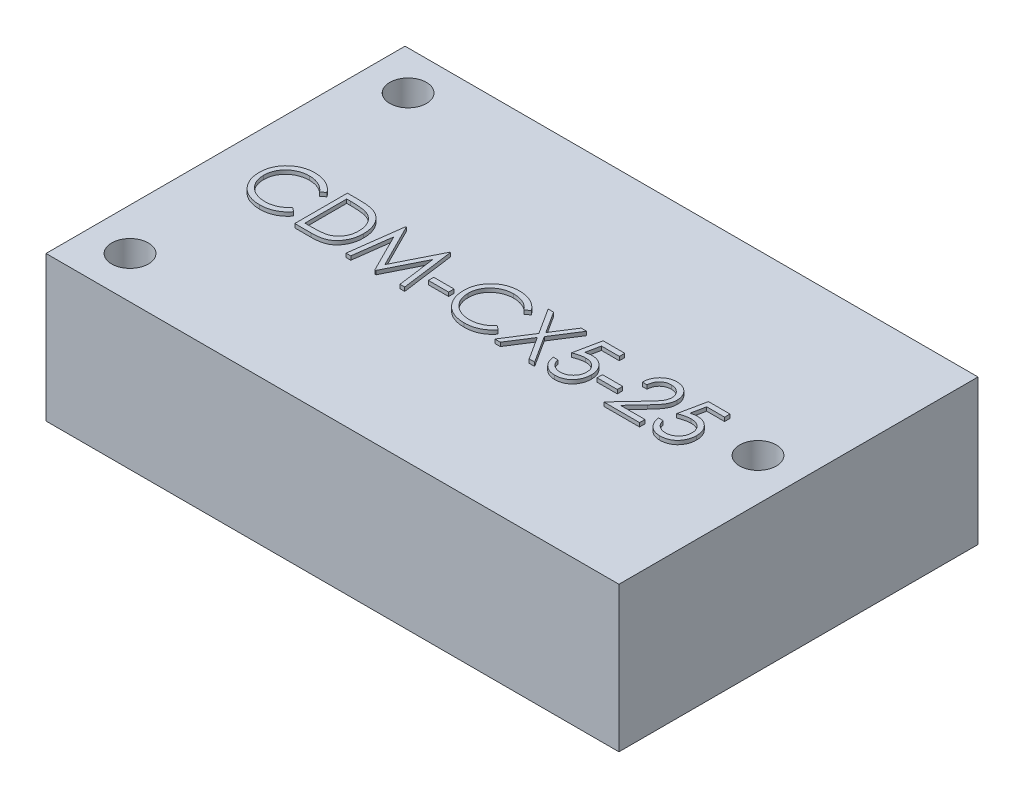
from build123d import *

# Parameters (mm, degrees)
SKETCH1_W           = 38.1
SKETCH1_H           = 23.876
SKETCH1_R           = 1.2192
BOSS_EXTRUDE1_DEPTH = 9.652
SKETCH2_W           = 1.346153846
SKETCH2_H           = 0.358974359
BOSS_EXTRUDE2_DEPTH = 0.254


with BuildPart() as part:
    # Sketch1 → Boss-Extrude1 (new body)
    with BuildSketch(Plane(origin=(0, 0, 0), x_dir=(1, 0, 0), z_dir=(0, 1, 0))):
        Rectangle(SKETCH1_W, SKETCH1_H)
        with Locations((-16.256, 9.3472)):
            Circle(SKETCH1_R, mode=Mode.SUBTRACT)
        with Locations((-16.256, -9.144)):
            Circle(SKETCH1_R, mode=Mode.SUBTRACT)
        with Locations((16.256, 0.1016)):
            Circle(SKETCH1_R, mode=Mode.SUBTRACT)
    extrude(amount=-BOSS_EXTRUDE1_DEPTH)

    # Sketch2 → Boss-Extrude2 (add)
    with BuildSketch(Plane(origin=(0, 0, 0), x_dir=(1, 0, 0), z_dir=(0, 1, 0))):
        with BuildLine():
            Line((-12.967255042, 0.660782807), (-13.242094786, 0.450446269))
            add(Edge.make_bspline(
                [(-13.242094786, 0.450446269), (-13.261700674, 0.473812239), (-13.300648121, 0.520229154), (-13.363307324, 0.585408699), (-13.428608966, 0.64647396), (-13.496528088, 0.70371584), (-13.568287207, 0.755132606), (-13.642148006, 0.803403708), (-13.719346051, 0.846671446), (-13.826097786, 0.899134433), (-13.965745634, 0.953880588), (-14.141540473, 0.999783819), (-14.325051572, 1.029004995), (-14.450249171, 1.032169836), (-14.513929722, 1.033779602)],
                knots=[0, 0, 0, 0, 9.1485e-05, 0.000181737, 0.000271024, 0.000359627, 0.000447979, 0.000535687, 0.000624217, 0.000713268, 0.000892422, 0.00107303, 0.001257466, 0.001448389, 0.001448389, 0.001448389, 0.001448389], degree=3))
            add(Edge.make_bspline(
                [(-14.513929722, 1.033779602), (-14.549013021, 1.03337564), (-14.618854014, 1.032571464), (-14.722502487, 1.021962338), (-14.824215538, 1.007051128), (-14.923927005, 0.984925805), (-15.021509963, 0.956953186), (-15.117602365, 0.923527772), (-15.210812965, 0.882172932), (-15.302431203, 0.836464672), (-15.390210414, 0.784837228), (-15.473265462, 0.728523876), (-15.55129343, 0.668154779), (-15.624356042, 0.603503673), (-15.69252799, 0.534861712), (-15.755315301, 0.461497371), (-15.812500711, 0.383645197), (-15.865217736, 0.30233179), (-15.91243047, 0.217793998), (-15.951960349, 0.129718928), (-15.986965471, 0.039614825), (-16.014664714, -0.053536336), (-16.036589231, -0.149079102), (-16.051716894, -0.24726989), (-16.062205365, -0.347903569), (-16.063005542, -0.416112882), (-16.063408888, -0.450495238)],
                knots=[0, 0, 0, 0, 0.000105206, 0.000209435, 0.000312261, 0.00041348, 0.000515565, 0.000616682, 0.000718413, 0.000821258, 0.000923708, 0.001023662, 0.001122111, 0.001219464, 0.00131614, 0.001412112, 0.001508869, 0.001605718, 0.001702691, 0.001799013, 0.001895107, 0.001992482, 0.002090281, 0.00218895, 0.002290387, 0.00239349, 0.00239349, 0.00239349, 0.00239349], degree=3))
            add(Edge.make_bspline(
                [(-16.063408888, -0.450495238), (-16.062147069, -0.502226558), (-16.059669655, -0.603794142), (-16.037621321, -0.752564753), (-16.00411623, -0.895085427), (-15.953900653, -1.030465269), (-15.891981602, -1.160373627), (-15.813740991, -1.282612481), (-15.723124453, -1.399029045), (-15.618850034, -1.506871993), (-15.504444218, -1.605385718), (-15.381696306, -1.6921363), (-15.250912019, -1.764451182), (-15.113535388, -1.824627129), (-14.968509274, -1.870883856), (-14.816094472, -1.90344798), (-14.656622477, -1.92469016), (-14.547653077, -1.926723848), (-14.492194946, -1.927758859)],
                knots=[0, 0, 0, 0, 0.000155106, 0.000304531, 0.000450265, 0.000593548, 0.000736853, 0.000881182, 0.001028026, 0.001178769, 0.001330408, 0.001480379, 0.001628835, 0.001777978, 0.001929641, 0.002084627, 0.002245075, 0.00241136, 0.00241136, 0.00241136, 0.00241136], degree=3))
            add(Edge.make_bspline(
                [(-14.492194946, -1.927758859), (-14.431092257, -1.92607008), (-14.310827548, -1.922746157), (-14.134459522, -1.894586908), (-13.965623756, -1.84892899), (-13.80431117, -1.785031068), (-13.650976523, -1.70196578), (-13.505379863, -1.601267903), (-13.367398293, -1.48197957), (-13.28442701, -1.390896442), (-13.242094786, -1.344425526)],
                knots=[0, 0, 0, 0, 0.00018322, 0.00036062, 0.000534275, 0.000707044, 0.000879893, 0.001056289, 0.001237208, 0.001425665, 0.001425665, 0.001425665, 0.001425665], degree=3))
            Line((-13.242094786, -1.344425526), (-12.967255042, -1.552658699))
            add(Edge.make_bspline(
                [(-12.967255042, -1.552658699), (-12.989373152, -1.581197151), (-13.033503427, -1.638137357), (-13.104961444, -1.718409067), (-13.180238742, -1.793913103), (-13.259894452, -1.864040724), (-13.343012243, -1.930195189), (-13.431084556, -1.990497021), (-13.522953588, -2.045787905), (-13.618308067, -2.09641483), (-13.71704668, -2.141332077), (-13.819051115, -2.179785844), (-13.92388169, -2.212910734), (-14.031543199, -2.240162671), (-14.142258956, -2.261433754), (-14.25562943, -2.275653429), (-14.371899305, -2.285395344), (-14.450340726, -2.28628326), (-14.490091581, -2.286733218)],
                knots=[0, 0, 0, 0, 0.000108293, 0.000216068, 0.000322162, 0.000427957, 0.000534281, 0.00064066, 0.000747915, 0.000855806, 0.000964371, 0.001073102, 0.001182643, 0.001294024, 0.001406092, 0.001520624, 0.001636667, 0.001755891, 0.001755891, 0.001755891, 0.001755891], degree=3))
            add(Edge.make_bspline(
                [(-14.490091581, -2.286733218), (-14.527735248, -2.286471226), (-14.602170938, -2.285953168), (-14.712069689, -2.277561001), (-14.81905927, -2.266111264), (-14.922833896, -2.248871133), (-15.023959871, -2.228526793), (-15.121520456, -2.201255536), (-15.216475666, -2.170706369), (-15.308444007, -2.134801383), (-15.397503707, -2.0942852), (-15.483367518, -2.048493641), (-15.56599595, -1.997811777), (-15.646201371, -1.943356766), (-15.722798955, -1.883379464), (-15.79645248, -1.81871283), (-15.867574956, -1.749574819), (-15.911577641, -1.699719966), (-15.933701356, -1.674653892)],
                knots=[0, 0, 0, 0, 0.0001129, 0.000223246, 0.000330481, 0.000435603, 0.000538732, 0.000639764, 0.000739316, 0.000837878, 0.000935767, 0.001032686, 0.001129604, 0.00122645, 0.001323362, 0.001421241, 0.001520399, 0.001620667, 0.001620667, 0.001620667, 0.001620667], degree=3))
            add(Edge.make_bspline(
                [(-15.933701356, -1.674653892), (-15.969137, -1.631112703), (-16.039580477, -1.544555992), (-16.12970616, -1.404270011), (-16.206853715, -1.257801802), (-16.269229636, -1.104381873), (-16.317992369, -0.944354486), (-16.351773564, -0.777638972), (-16.373725169, -0.604391029), (-16.376235458, -0.486554241), (-16.377511453, -0.426657097)],
                knots=[0, 0, 0, 0, 0.000168306, 0.00033458, 0.000499224, 0.000664315, 0.00083066, 0.00100034, 0.001174094, 0.001353718, 0.001353718, 0.001353718, 0.001353718], degree=3))
            add(Edge.make_bspline(
                [(-16.377511453, -0.426657097), (-16.375956259, -0.363701643), (-16.372896513, -0.239840719), (-16.346900717, -0.058066765), (-16.305081921, 0.116084634), (-16.245685032, 0.282288378), (-16.170379681, 0.441418658), (-16.077353067, 0.592259863), (-15.967685925, 0.735776663), (-15.842238357, 0.869791414), (-15.704671022, 0.992330767), (-15.557352208, 1.100136971), (-15.400570261, 1.189854487), (-15.23605241, 1.264850649), (-15.062566728, 1.322495112), (-14.880483359, 1.362848299), (-14.690144444, 1.387965415), (-14.560282018, 1.391140623), (-14.494298311, 1.392753961)],
                knots=[0, 0, 0, 0, 0.000188789, 0.000371431, 0.000549644, 0.000725278, 0.00089996, 0.001076844, 0.001255917, 0.001440951, 0.001626689, 0.001807878, 0.001987546, 0.002167657, 0.002349462, 0.002534866, 0.002726448, 0.002924344, 0.002924344, 0.002924344, 0.002924344], degree=3))
            add(Edge.make_bspline(
                [(-14.494298311, 1.392753961), (-14.45408384, 1.392271823), (-14.374483342, 1.391317479), (-14.25673069, 1.382011337), (-14.142088363, 1.366497731), (-14.030477381, 1.345381661), (-13.921354765, 1.319174339), (-13.815554524, 1.285034041), (-13.712455837, 1.24599751), (-13.612708929, 1.201039044), (-13.516792379, 1.150572302), (-13.42473606, 1.095156679), (-13.337271201, 1.034860873), (-13.253782353, 0.970197698), (-13.175666142, 0.899799139), (-13.100704663, 0.825601543), (-13.031443585, 0.745467718), (-12.98869039, 0.689062784), (-12.967255042, 0.660782807)],
                knots=[0, 0, 0, 0, 0.000120626, 0.000238766, 0.000354085, 0.000467531, 0.000579423, 0.000690512, 0.000800803, 0.000910007, 0.001018518, 0.001125773, 0.001232152, 0.001337058, 0.001442329, 0.001547432, 0.001653292, 0.001759736, 0.001759736, 0.001759736, 0.001759736], degree=3))
        make_face()
        with BuildLine():
            Line((-12.249306324, -2.196989629), (-12.249306324, 1.303010371))
            Line((-12.249306324, 1.303010371), (-11.542575555, 1.303010371))
            add(Edge.make_bspline(
                [(-11.542575555, 1.303010371), (-11.481106567, 1.302567801), (-11.362348802, 1.301712758), (-11.190736354, 1.296291367), (-11.031952592, 1.286700901), (-10.886519733, 1.272731375), (-10.754038521, 1.255578342), (-10.634879912, 1.234077937), (-10.52842777, 1.208689767), (-10.462958329, 1.187044317), (-10.431998632, 1.176808448)],
                knots=[0, 0, 0, 0, 0.000184407, 0.000356273, 0.000515031, 0.000661537, 0.000794508, 0.000915664, 0.001024665, 0.001122454, 0.001122454, 0.001122454, 0.001122454], degree=3))
            add(Edge.make_bspline(
                [(-10.431998632, 1.176808448), (-10.391503893, 1.161377743), (-10.3114327, 1.130866249), (-10.197425578, 1.073309947), (-10.090100215, 1.008096845), (-9.98888107, 0.935140983), (-9.896080244, 0.852376634), (-9.808072347, 0.763319549), (-9.728457623, 0.664731208), (-9.655549327, 0.55865622), (-9.589813668, 0.446344168), (-9.53267451, 0.32800906), (-9.485220516, 0.204251851), (-9.44582729, 0.075416703), (-9.414780832, -0.058779674), (-9.393598901, -0.19849354), (-9.379627911, -0.34317273), (-9.378223859, -0.441347194), (-9.377511453, -0.491160302)],
                knots=[0, 0, 0, 0, 0.000129935, 0.000256923, 0.000382457, 0.000506429, 0.000630624, 0.000755071, 0.000881654, 0.001010204, 0.001140916, 0.00127168, 0.001403968, 0.001538146, 0.001675568, 0.001816774, 0.001961818, 0.002111216, 0.002111216, 0.002111216, 0.002111216], degree=3))
            add(Edge.make_bspline(
                [(-9.377511453, -0.491160302), (-9.37814042, -0.53442154), (-9.379379866, -0.619672329), (-9.390509182, -0.745313225), (-9.406685502, -0.867226796), (-9.4317297, -0.984832496), (-9.462132213, -1.099160714), (-9.501096365, -1.208992958), (-9.545731861, -1.315336768), (-9.597781739, -1.416754244), (-9.654923124, -1.512837616), (-9.716244868, -1.603413144), (-9.781681563, -1.687188366), (-9.851857196, -1.764416978), (-9.925864912, -1.834982556), (-10.004189243, -1.899474572), (-10.087032294, -1.956631127), (-10.174023016, -2.008698235), (-10.267699146, -2.05411859), (-10.369835012, -2.0925486), (-10.48086619, -2.124395215), (-10.600520147, -2.150966111), (-10.729003624, -2.172043414), (-10.86644259, -2.186169806), (-11.01262588, -2.195722739), (-11.113005145, -2.196559132), (-11.164670908, -2.196989629)],
                knots=[0, 0, 0, 0, 0.000129755, 0.000255696, 0.000378151, 0.000498469, 0.000616165, 0.000732801, 0.000847787, 0.000961923, 0.00107447, 0.001182981, 0.001289856, 0.001393094, 0.001495748, 0.001596383, 0.00169713, 0.001797413, 0.001900265, 0.002008995, 0.002124372, 0.002246504, 0.002376522, 0.002514729, 0.002660846, 0.00281582, 0.00281582, 0.00281582, 0.00281582], degree=3))
            Line((-11.164670908, -2.196989629), (-12.249306324, -2.196989629))
        make_face()
        with BuildLine():
            Line((-11.93520376, -1.83801527), (-11.533460972, -1.83801527))
            add(Edge.make_bspline(
                [(-11.533460972, -1.83801527), (-11.475732601, -1.837767173), (-11.364699803, -1.837289993), (-11.205041805, -1.83310279), (-11.059162409, -1.826260853), (-10.927040899, -1.816685775), (-10.808751875, -1.80401716), (-10.704048125, -1.789892257), (-10.613272867, -1.772294806), (-10.55834343, -1.756343847), (-10.53296017, -1.748972802)],
                knots=[0, 0, 0, 0, 0.000173183, 0.000333094, 0.000479096, 0.000611272, 0.000730431, 0.000835931, 0.000928194, 0.001007458, 0.001007458, 0.001007458, 0.001007458], degree=3))
            add(Edge.make_bspline(
                [(-10.53296017, -1.748972802), (-10.501011808, -1.737721244), (-10.43787817, -1.71548687), (-10.346997085, -1.674929209), (-10.26224008, -1.626887139), (-10.182130055, -1.573484865), (-10.1078034, -1.512838863), (-10.038379283, -1.446267875), (-9.973997482, -1.373433099), (-9.915323174, -1.294424938), (-9.86281487, -1.209735142), (-9.817343641, -1.120196309), (-9.777492109, -1.026789498), (-9.746213516, -0.92808034), (-9.721697932, -0.824951281), (-9.704333244, -0.717395068), (-9.69351852, -0.605431786), (-9.692257072, -0.529279662), (-9.691614017, -0.49045918)],
                knots=[0, 0, 0, 0, 0.000101593, 0.000200759, 0.000298073, 0.000393552, 0.000489254, 0.000585454, 0.000681817, 0.000780535, 0.000880346, 0.000980374, 0.001081551, 0.001184655, 0.001290601, 0.001399295, 0.001511268, 0.001627707, 0.001627707, 0.001627707, 0.001627707], degree=3))
            add(Edge.make_bspline(
                [(-9.691614017, -0.49045918), (-9.692127304, -0.4495257), (-9.693135662, -0.369111515), (-9.705809972, -0.25112082), (-9.724331527, -0.13764017), (-9.751115214, -0.028661974), (-9.785246092, 0.076026378), (-9.827840734, 0.175845888), (-9.876507353, 0.271850757), (-9.93441069, 0.361825123), (-9.997826284, 0.446918232), (-10.068204163, 0.524873148), (-10.144426201, 0.595867448), (-10.225661051, 0.661006761), (-10.31419815, 0.717670436), (-10.407951841, 0.768357117), (-10.508297512, 0.811373009), (-10.578110208, 0.834251872), (-10.613589177, 0.845878961)],
                knots=[0, 0, 0, 0, 0.000122746, 0.000241136, 0.000355593, 0.000467485, 0.000577457, 0.000685538, 0.00079278, 0.000899951, 0.001006101, 0.00111085, 0.001214524, 0.001318328, 0.001422759, 0.001529413, 0.00163777, 0.001749741, 0.001749741, 0.001749741, 0.001749741], degree=3))
            add(Edge.make_bspline(
                [(-10.613589177, 0.845878961), (-10.642940323, 0.853995389), (-10.705348914, 0.871253141), (-10.807188378, 0.890078514), (-10.921803527, 0.906683013), (-11.049703228, 0.920741052), (-11.190741687, 0.930828374), (-11.345027375, 0.938399688), (-11.51262698, 0.943506321), (-11.628809514, 0.943855028), (-11.68911001, 0.944036012)],
                knots=[0, 0, 0, 0, 9.1321e-05, 0.000194173, 0.000310382, 0.000438754, 0.000580072, 0.000734511, 0.000902151, 0.001083046, 0.001083046, 0.001083046, 0.001083046], degree=3))
            Line((-11.68911001, 0.944036012), (-11.93520376, 0.944036012))
            Line((-11.93520376, 0.944036012), (-11.93520376, -1.83801527))
        make_face(mode=Mode.SUBTRACT)
        Polygon((-8.839049914, -2.196989629), (-8.377010651, 1.303010371), (-8.332138856, 1.303010371), (-6.887126837, -1.5687845), (-5.445620427, 1.303010371), (-5.40004751, 1.303010371), (-4.93520376, -2.196989629), (-5.250708568, -2.196989629), (-5.585844786, 0.321439858), (-6.84926626, -2.196989629), (-6.920079561, -2.196989629), (-8.188408888, 0.327048833), (-8.522843985, -2.196989629), align=None)
        with Locations((-3.858280683, -0.850835783)):
            Rectangle(SKETCH2_W, SKETCH2_H)
        with BuildLine():
            Line((0.628898804, 0.660782807), (0.35405906, 0.450446269))
            add(Edge.make_bspline(
                [(0.35405906, 0.450446269), (0.334453172, 0.473812239), (0.295505725, 0.520229154), (0.232846523, 0.585408699), (0.16754488, 0.64647396), (0.099625758, 0.70371584), (0.027866639, 0.755132606), (-0.04599416, 0.803403708), (-0.123192205, 0.846671446), (-0.22994394, 0.899134433), (-0.369591788, 0.953880588), (-0.545386627, 0.999783819), (-0.728897725, 1.029004995), (-0.854095325, 1.032169836), (-0.917775876, 1.033779602)],
                knots=[0, 0, 0, 0, 9.1485e-05, 0.000181737, 0.000271024, 0.000359627, 0.000447979, 0.000535687, 0.000624217, 0.000713268, 0.000892422, 0.00107303, 0.001257466, 0.001448389, 0.001448389, 0.001448389, 0.001448389], degree=3))
            add(Edge.make_bspline(
                [(-0.917775876, 1.033779602), (-0.952859175, 1.03337564), (-1.022700168, 1.032571464), (-1.126348641, 1.021962338), (-1.228061692, 1.007051128), (-1.327773158, 0.984925805), (-1.425356117, 0.956953186), (-1.521448519, 0.923527772), (-1.614659119, 0.882172932), (-1.706277357, 0.836464672), (-1.794056568, 0.784837228), (-1.877111616, 0.728523876), (-1.955139584, 0.668154779), (-2.028202196, 0.603503673), (-2.096374144, 0.534861712), (-2.159161455, 0.461497371), (-2.216346865, 0.383645197), (-2.26906389, 0.30233179), (-2.316276624, 0.217793998), (-2.355806503, 0.129718928), (-2.390811625, 0.039614825), (-2.418510868, -0.053536336), (-2.440435385, -0.149079102), (-2.455563048, -0.24726989), (-2.466051519, -0.347903569), (-2.466851696, -0.416112882), (-2.467255042, -0.450495238)],
                knots=[0, 0, 0, 0, 0.000105206, 0.000209435, 0.000312261, 0.00041348, 0.000515565, 0.000616682, 0.000718413, 0.000821258, 0.000923708, 0.001023662, 0.001122111, 0.001219464, 0.00131614, 0.001412112, 0.001508869, 0.001605718, 0.001702691, 0.001799013, 0.001895107, 0.001992482, 0.002090281, 0.00218895, 0.002290387, 0.00239349, 0.00239349, 0.00239349, 0.00239349], degree=3))
            add(Edge.make_bspline(
                [(-2.467255042, -0.450495238), (-2.465993223, -0.502226558), (-2.463515809, -0.603794142), (-2.441467475, -0.752564753), (-2.407962384, -0.895085427), (-2.357746807, -1.030465269), (-2.295827756, -1.160373627), (-2.217587145, -1.282612481), (-2.126970607, -1.399029045), (-2.022696188, -1.506871993), (-1.908290372, -1.605385718), (-1.78554246, -1.6921363), (-1.654758172, -1.764451182), (-1.517381542, -1.824627129), (-1.372355428, -1.870883856), (-1.219940626, -1.90344798), (-1.060468631, -1.92469016), (-0.951499231, -1.926723848), (-0.8960411, -1.927758859)],
                knots=[0, 0, 0, 0, 0.000155106, 0.000304531, 0.000450265, 0.000593548, 0.000736853, 0.000881182, 0.001028026, 0.001178769, 0.001330408, 0.001480379, 0.001628835, 0.001777978, 0.001929641, 0.002084627, 0.002245075, 0.00241136, 0.00241136, 0.00241136, 0.00241136], degree=3))
            add(Edge.make_bspline(
                [(-0.8960411, -1.927758859), (-0.834938411, -1.92607008), (-0.714673702, -1.922746157), (-0.538305676, -1.894586908), (-0.36946991, -1.84892899), (-0.208157324, -1.785031068), (-0.054822677, -1.70196578), (0.090773983, -1.601267903), (0.228755553, -1.48197957), (0.311726836, -1.390896442), (0.35405906, -1.344425526)],
                knots=[0, 0, 0, 0, 0.00018322, 0.00036062, 0.000534275, 0.000707044, 0.000879893, 0.001056289, 0.001237208, 0.001425665, 0.001425665, 0.001425665, 0.001425665], degree=3))
            Line((0.35405906, -1.344425526), (0.628898804, -1.552658699))
            add(Edge.make_bspline(
                [(0.628898804, -1.552658699), (0.606780694, -1.581197151), (0.562650419, -1.638137357), (0.491192402, -1.718409067), (0.415915104, -1.793913103), (0.336259394, -1.864040724), (0.253141603, -1.930195189), (0.16506929, -1.990497021), (0.073200258, -2.045787905), (-0.022154221, -2.09641483), (-0.120892834, -2.141332077), (-0.222897269, -2.179785844), (-0.327727844, -2.212910734), (-0.435389353, -2.240162671), (-0.546105109, -2.261433754), (-0.659475584, -2.275653429), (-0.775745459, -2.285395344), (-0.85418688, -2.28628326), (-0.893937735, -2.286733218)],
                knots=[0, 0, 0, 0, 0.000108293, 0.000216068, 0.000322162, 0.000427957, 0.000534281, 0.00064066, 0.000747915, 0.000855806, 0.000964371, 0.001073102, 0.001182643, 0.001294024, 0.001406092, 0.001520624, 0.001636667, 0.001755891, 0.001755891, 0.001755891, 0.001755891], degree=3))
            add(Edge.make_bspline(
                [(-0.893937735, -2.286733218), (-0.931581402, -2.286471226), (-1.006017092, -2.285953168), (-1.115915843, -2.277561001), (-1.222905424, -2.266111264), (-1.32668005, -2.248871133), (-1.427806025, -2.228526793), (-1.52536661, -2.201255536), (-1.62032182, -2.170706369), (-1.712290161, -2.134801383), (-1.80134986, -2.0942852), (-1.887213672, -2.048493641), (-1.969842104, -1.997811777), (-2.050047525, -1.943356766), (-2.126645109, -1.883379464), (-2.200298634, -1.81871283), (-2.27142111, -1.749574819), (-2.315423795, -1.699719966), (-2.33754751, -1.674653892)],
                knots=[0, 0, 0, 0, 0.0001129, 0.000223246, 0.000330481, 0.000435603, 0.000538732, 0.000639764, 0.000739316, 0.000837878, 0.000935767, 0.001032686, 0.001129604, 0.00122645, 0.001323362, 0.001421241, 0.001520399, 0.001620667, 0.001620667, 0.001620667, 0.001620667], degree=3))
            add(Edge.make_bspline(
                [(-2.33754751, -1.674653892), (-2.372983154, -1.631112703), (-2.443426631, -1.544555992), (-2.533552314, -1.404270011), (-2.610699869, -1.257801802), (-2.67307579, -1.104381873), (-2.721838523, -0.944354486), (-2.755619718, -0.777638972), (-2.777571323, -0.604391029), (-2.780081612, -0.486554241), (-2.781357606, -0.426657097)],
                knots=[0, 0, 0, 0, 0.000168306, 0.00033458, 0.000499224, 0.000664315, 0.00083066, 0.00100034, 0.001174094, 0.001353718, 0.001353718, 0.001353718, 0.001353718], degree=3))
            add(Edge.make_bspline(
                [(-2.781357606, -0.426657097), (-2.779802413, -0.363701643), (-2.776742667, -0.239840719), (-2.750746871, -0.058066765), (-2.708928075, 0.116084634), (-2.649531186, 0.282288378), (-2.574225835, 0.441418658), (-2.481199221, 0.592259863), (-2.371532079, 0.735776663), (-2.246084511, 0.869791414), (-2.108517176, 0.992330767), (-1.961198362, 1.100136971), (-1.804416415, 1.189854487), (-1.639898563, 1.264850649), (-1.466412882, 1.322495112), (-1.284329513, 1.362848299), (-1.093990598, 1.387965415), (-0.964128172, 1.391140623), (-0.898144465, 1.392753961)],
                knots=[0, 0, 0, 0, 0.000188789, 0.000371431, 0.000549644, 0.000725278, 0.00089996, 0.001076844, 0.001255917, 0.001440951, 0.001626689, 0.001807878, 0.001987546, 0.002167657, 0.002349462, 0.002534866, 0.002726448, 0.002924344, 0.002924344, 0.002924344, 0.002924344], degree=3))
            add(Edge.make_bspline(
                [(-0.898144465, 1.392753961), (-0.857929993, 1.392271823), (-0.778329496, 1.391317479), (-0.660576844, 1.382011337), (-0.545934517, 1.366497731), (-0.434323535, 1.345381661), (-0.325200918, 1.319174339), (-0.219400678, 1.285034041), (-0.116301991, 1.24599751), (-0.016555083, 1.201039044), (0.079361468, 1.150572302), (0.171417786, 1.095156679), (0.258882645, 1.034860873), (0.342371493, 0.970197698), (0.420487704, 0.899799139), (0.495449183, 0.825601543), (0.564710261, 0.745467718), (0.607463456, 0.689062784), (0.628898804, 0.660782807)],
                knots=[0, 0, 0, 0, 0.000120626, 0.000238766, 0.000354085, 0.000467531, 0.000579423, 0.000690512, 0.000800803, 0.000910007, 0.001018518, 0.001125773, 0.001232152, 0.001337058, 0.001442329, 0.001547432, 0.001653292, 0.001759736, 0.001759736, 0.001759736, 0.001759736], degree=3))
        make_face()
        Polygon((1.10005265, 1.303010371), (1.462532618, 1.303010371), (2.378898804, -0.128680334), (3.29526499, 1.303010371), (3.657744958, 1.303010371), (2.560489349, -0.411933539), (3.702616753, -2.196989629), (3.340136785, -2.196989629), (2.378898804, -0.695186744), (1.417660823, -2.196989629), (1.055180855, -2.196989629), (2.198009381, -0.411933539), align=None)
        with BuildLine():
            Line((6.193001368, 1.303010371), (6.193001368, 0.944036012))
            Line((6.193001368, 0.944036012), (5.00249656, 0.944036012))
            Line((5.00249656, 0.944036012), (4.813894797, 0.023463096))
            add(Edge.make_bspline(
                [(4.813894797, 0.023463096), (4.850950672, 0.033693367), (4.922740568, 0.053512901), (5.028700429, 0.075518672), (5.129292632, 0.088784116), (5.194568003, 0.090595426), (5.226154413, 0.09147191)],
                knots=[0, 0, 0, 0, 0.000115302, 0.000223379, 0.000324431, 0.000419176, 0.000419176, 0.000419176, 0.000419176], degree=3))
            add(Edge.make_bspline(
                [(5.226154413, 0.09147191), (5.265238153, 0.090625974), (5.34208655, 0.088962653), (5.454525497, 0.072990804), (5.56185839, 0.047850889), (5.66386076, 0.012730367), (5.760721311, -0.032179366), (5.851548872, -0.088279306), (5.937706785, -0.153812637), (6.017649379, -0.229157649), (6.090173688, -0.312079266), (6.153939677, -0.401237137), (6.208102267, -0.495764799), (6.251663022, -0.596565408), (6.286447357, -0.702524561), (6.309599351, -0.814757144), (6.32501606, -0.932205264), (6.326738447, -1.012509834), (6.327616753, -1.053459981)],
                knots=[0, 0, 0, 0, 0.00011719, 0.000230425, 0.000339944, 0.000447481, 0.000553499, 0.000659556, 0.000767111, 0.000877722, 0.000988528, 0.001097091, 0.001206056, 0.001314692, 0.001425996, 0.001539995, 0.001658004, 0.001780798, 0.001780798, 0.001780798, 0.001780798], degree=3))
            add(Edge.make_bspline(
                [(6.327616753, -1.053459981), (6.326951677, -1.081982202), (6.325630515, -1.138641189), (6.318911927, -1.22278539), (6.305976211, -1.305148223), (6.288608487, -1.385740615), (6.266066069, -1.464409987), (6.238777015, -1.541381515), (6.205380988, -1.616176122), (6.168749612, -1.689501517), (6.127503134, -1.759700024), (6.081724627, -1.82534901), (6.033359136, -1.887433292), (5.98131775, -1.945287025), (5.925116755, -1.998530043), (5.865436788, -2.047478324), (5.802754069, -2.092959655), (5.736098827, -2.13312785), (5.666956344, -2.170090806), (5.594328127, -2.200414343), (5.519867426, -2.227524871), (5.442502551, -2.249134399), (5.362408738, -2.266066953), (5.279453963, -2.277567554), (5.194073293, -2.285943992), (5.13619828, -2.286468348), (5.106963708, -2.286733218)],
                knots=[0, 0, 0, 0, 8.5583e-05, 0.000170009, 0.000253005, 0.000335518, 0.000417186, 0.000498352, 0.000580291, 0.000662755, 0.000744161, 0.000824288, 0.000902692, 0.000980133, 0.001057498, 0.001134702, 0.00121156, 0.001289599, 0.001368002, 0.001446531, 0.001525481, 0.001605609, 0.001687289, 0.001770875, 0.001856759, 0.001944425, 0.001944425, 0.001944425, 0.001944425], degree=3))
            add(Edge.make_bspline(
                [(5.106963708, -2.286733218), (5.072089527, -2.28604238), (5.003478696, -2.284683238), (4.902958129, -2.270464753), (4.806243524, -2.250100837), (4.714113422, -2.219464567), (4.625742159, -2.181077272), (4.542319441, -2.132561101), (4.461713665, -2.077581997), (4.387201628, -2.012701644), (4.318045515, -1.941785962), (4.256139006, -1.864828321), (4.201005429, -1.783098879), (4.153527682, -1.696200725), (4.113029661, -1.604362194), (4.081214672, -1.507239193), (4.055536318, -1.405339189), (4.044672897, -1.335185678), (4.039155214, -1.299553731)],
                knots=[0, 0, 0, 0, 0.000104552, 0.000205693, 0.000304023, 0.000400691, 0.00049644, 0.000592535, 0.000689779, 0.000788716, 0.000888377, 0.000986596, 0.001084603, 0.001183757, 0.001283279, 0.001385267, 0.001490017, 0.001598135, 0.001598135, 0.001598135, 0.001598135], degree=3))
            Line((4.039155214, -1.299553731), (4.353257778, -1.299553731))
            add(Edge.make_bspline(
                [(4.353257778, -1.299553731), (4.360986336, -1.332930184), (4.375841052, -1.397081579), (4.408446801, -1.48721292), (4.448312676, -1.567532144), (4.495717025, -1.639101727), (4.552267055, -1.701510724), (4.616796484, -1.757127786), (4.689144207, -1.807302915), (4.769537437, -1.849125683), (4.854350516, -1.884794436), (4.943117726, -1.908546131), (5.033422073, -1.925247024), (5.094500443, -1.926918785), (5.125192874, -1.927758859)],
                knots=[0, 0, 0, 0, 0.000102709, 0.000197412, 0.000286774, 0.000371169, 0.000454082, 0.000538572, 0.000626283, 0.000717552, 0.000809994, 0.00090168, 0.00099274, 0.001084718, 0.001084718, 0.001084718, 0.001084718], degree=3))
            add(Edge.make_bspline(
                [(5.125192874, -1.927758859), (5.155151319, -1.926938082), (5.214139741, -1.925321963), (5.300951128, -1.912882951), (5.384764002, -1.89372538), (5.464751359, -1.865055525), (5.542312898, -1.830210806), (5.615486669, -1.785495731), (5.686389546, -1.734035712), (5.752817679, -1.675079082), (5.813657129, -1.610109387), (5.86741325, -1.540631994), (5.912190163, -1.466515147), (5.949924272, -1.389041995), (5.978577571, -1.307363437), (5.999018552, -1.221862262), (6.011021611, -1.132327282), (6.012672791, -1.071257972), (6.013514189, -1.040138667)],
                knots=[0, 0, 0, 0, 8.9842e-05, 0.0001769, 0.000262612, 0.000347317, 0.000431396, 0.000517249, 0.000604055, 0.000693954, 0.000783242, 0.000870748, 0.000956963, 0.001042571, 0.001128832, 0.00121607, 0.001305907, 0.001399251, 0.001399251, 0.001399251, 0.001399251], degree=3))
            add(Edge.make_bspline(
                [(6.013514189, -1.040138667), (6.012855709, -1.012062916), (6.011566829, -0.957108626), (6.001036259, -0.87670942), (5.982719287, -0.800636378), (5.957295407, -0.728522144), (5.925015899, -0.660298701), (5.885569587, -0.595895641), (5.838216189, -0.536161808), (5.7841243, -0.481069254), (5.724866259, -0.43022438), (5.659422516, -0.386880293), (5.58916259, -0.350416375), (5.51493299, -0.318948377), (5.434968092, -0.296347632), (5.350851459, -0.279379746), (5.261674751, -0.269564384), (5.200704063, -0.268202495), (5.169363547, -0.267502449)],
                knots=[0, 0, 0, 0, 8.4208e-05, 0.000164824, 0.000242709, 0.000318547, 0.000393815, 0.000468731, 0.000544614, 0.00062196, 0.000700062, 0.000778428, 0.000856831, 0.000937299, 0.001019835, 0.001105635, 0.00119452, 0.001288536, 0.001288536, 0.001288536, 0.001288536], degree=3))
            add(Edge.make_bspline(
                [(5.169363547, -0.267502449), (5.142234619, -0.26808304), (5.086220263, -0.269281814), (5.000297437, -0.278108311), (4.910005714, -0.292347605), (4.815691218, -0.311933853), (4.71707071, -0.337564929), (4.614352309, -0.36827943), (4.507320043, -0.405001429), (4.435202318, -0.432733642), (4.398129573, -0.446989629)],
                knots=[0, 0, 0, 0, 8.1378e-05, 0.000168026, 0.000258858, 0.000355524, 0.000456875, 0.000564457, 0.000677092, 0.000796243, 0.000796243, 0.000796243, 0.000796243], degree=3))
            Line((4.398129573, -0.446989629), (4.757103932, 1.303010371))
            Line((4.757103932, 1.303010371), (6.193001368, 1.303010371))
        make_face()
        with Locations((7.359668035, -0.850835783)):
            Rectangle(SKETCH2_W, SKETCH2_H)
        with BuildLine():
            Line((8.750693676, 0.226087294), (8.436591112, 0.226087294))
            add(Edge.make_bspline(
                [(8.436591112, 0.226087294), (8.438638265, 0.267758182), (8.442658819, 0.349598697), (8.461487108, 0.468922603), (8.488427985, 0.582977402), (8.526519439, 0.690847316), (8.573825717, 0.793486123), (8.630555744, 0.890486139), (8.697749595, 0.981477327), (8.773956329, 1.065616171), (8.856724968, 1.142803742), (8.946030907, 1.209458984), (9.039875935, 1.265776656), (9.137975334, 1.312857898), (9.241435897, 1.348197743), (9.349318755, 1.374419383), (9.462097891, 1.390195729), (9.538937913, 1.391891514), (9.578017394, 1.392753961)],
                knots=[0, 0, 0, 0, 0.000125083, 0.00024566, 0.000361805, 0.000476223, 0.000588214, 0.000700404, 0.000812728, 0.00092691, 0.001040529, 0.001151727, 0.001260545, 0.001368429, 0.001477521, 0.001587884, 0.001701119, 0.00181831, 0.00181831, 0.00181831, 0.00181831], degree=3))
            add(Edge.make_bspline(
                [(9.578017394, 1.392753961), (9.616395468, 1.391855505), (9.691807012, 1.39009007), (9.801869027, 1.374929041), (9.906646321, 1.351183449), (10.005934088, 1.317868033), (10.098940152, 1.273083605), (10.186363197, 1.219286067), (10.269244008, 1.157066235), (10.343850791, 1.083812422), (10.412358871, 1.005610037), (10.471461126, 0.922122134), (10.522074289, 0.835892848), (10.564261969, 0.746264646), (10.595318108, 0.652393618), (10.618896316, 0.555646415), (10.63222373, 0.455021604), (10.634269153, 0.386915048), (10.63530906, 0.352289217)],
                knots=[0, 0, 0, 0, 0.000115089, 0.000226145, 0.000332614, 0.000437044, 0.000539592, 0.000641561, 0.000744629, 0.00084975, 0.000954621, 0.001056175, 0.001156101, 0.001254284, 0.001352726, 0.001452208, 0.001552655, 0.001656537, 0.001656537, 0.001656537, 0.001656537], degree=3))
            add(Edge.make_bspline(
                [(10.63530906, 0.352289217), (10.633615797, 0.303541383), (10.630258986, 0.206901169), (10.60154461, 0.064886306), (10.556698098, -0.072707113), (10.502700742, -0.183444415), (10.448228298, -0.272677908), (10.39914079, -0.346146613), (10.341675979, -0.425252082), (10.274997481, -0.509729419), (10.200484609, -0.600240324), (10.117462445, -0.69673012), (10.025338963, -0.798201889), (9.960680463, -0.867507491), (9.927176047, -0.903419917)],
                knots=[0, 0, 0, 0, 0.000146118, 0.000289672, 0.0004329, 0.00057934, 0.000657978, 0.000746456, 0.000844345, 0.000951219, 0.001069268, 0.00119604, 0.001333047, 0.001480391, 0.001480391, 0.001480391, 0.001480391], degree=3))
            Line((9.927176047, -0.903419917), (9.051474926, -1.83801527))
            Line((9.051474926, -1.83801527), (10.680180855, -1.83801527))
            Line((10.680180855, -1.83801527), (10.680180855, -2.196989629))
            Line((10.680180855, -2.196989629), (8.301975727, -2.196989629))
            Line((8.301975727, -2.196989629), (9.659347522, -0.748472))
            add(Edge.make_bspline(
                [(9.659347522, -0.748472), (9.692395409, -0.713973694), (9.755873636, -0.647709507), (9.845656213, -0.550966547), (9.926295201, -0.461217006), (9.998312594, -0.378630458), (10.060146099, -0.30199889), (10.115018331, -0.233804187), (10.158983922, -0.171049736), (10.206699318, -0.098309122), (10.252913299, -0.009496805), (10.292625655, 0.099036884), (10.316840504, 0.210764137), (10.319745339, 0.286266174), (10.321206496, 0.324244346)],
                knots=[0, 0, 0, 0, 0.000143319, 0.000275286, 0.00039593, 0.000505287, 0.000603949, 0.000691331, 0.000767782, 0.00083371, 0.000952247, 0.001067137, 0.001179618, 0.001293462, 0.001293462, 0.001293462, 0.001293462], degree=3))
            add(Edge.make_bspline(
                [(10.321206496, 0.324244346), (10.320570754, 0.348125744), (10.319317828, 0.395191394), (10.30826013, 0.464197153), (10.291549624, 0.530761967), (10.267604366, 0.595090586), (10.235997626, 0.656536238), (10.197524246, 0.715173719), (10.153134183, 0.771862684), (10.101782914, 0.825015982), (10.045371394, 0.873697187), (9.985777144, 0.916821273), (9.92272704, 0.952860384), (9.856486918, 0.982403881), (9.787241448, 1.005579262), (9.714856703, 1.021637841), (9.639532687, 1.031720325), (9.588099191, 1.033084497), (9.561891592, 1.033779602)],
                knots=[0, 0, 0, 0, 7.16e-05, 0.00014111, 0.00020913, 0.00027724, 0.000346538, 0.000415963, 0.000487357, 0.000562233, 0.000637292, 0.000710646, 0.000782564, 0.000854749, 0.000927915, 0.001001225, 0.001076884, 0.001155488, 0.001155488, 0.001155488, 0.001155488], degree=3))
            add(Edge.make_bspline(
                [(9.561891592, 1.033779602), (9.53452076, 1.03306457), (9.480768963, 1.031660365), (9.40184993, 1.021837701), (9.326564153, 1.00489186), (9.25472225, 0.981715186), (9.186202664, 0.952256637), (9.12133862, 0.915564892), (9.060275731, 0.871781399), (9.002899208, 0.822140843), (8.950035228, 0.766873242), (8.903588353, 0.705263278), (8.863004338, 0.638435863), (8.827595105, 0.566571313), (8.798839415, 0.489017533), (8.776866264, 0.406049828), (8.759479418, 0.318028446), (8.753670897, 0.257243361), (8.750693676, 0.226087294)],
                knots=[0, 0, 0, 0, 8.2106e-05, 0.000161243, 0.000238127, 0.000313291, 0.000387401, 0.000461495, 0.000536397, 0.000612445, 0.000688819, 0.000765383, 0.000843422, 0.000923066, 0.001005373, 0.001091093, 0.001180334, 0.001274175, 0.001274175, 0.001274175, 0.001274175], degree=3))
        make_face()
        with BuildLine():
            Line((13.193001368, 1.303010371), (13.193001368, 0.944036012))
            Line((13.193001368, 0.944036012), (12.00249656, 0.944036012))
            Line((12.00249656, 0.944036012), (11.813894797, 0.023463096))
            add(Edge.make_bspline(
                [(11.813894797, 0.023463096), (11.850950672, 0.033693367), (11.922740568, 0.053512901), (12.028700429, 0.075518672), (12.129292632, 0.088784116), (12.194568003, 0.090595426), (12.226154413, 0.09147191)],
                knots=[0, 0, 0, 0, 0.000115302, 0.000223379, 0.000324431, 0.000419176, 0.000419176, 0.000419176, 0.000419176], degree=3))
            add(Edge.make_bspline(
                [(12.226154413, 0.09147191), (12.265238153, 0.090625974), (12.34208655, 0.088962653), (12.454525497, 0.072990804), (12.56185839, 0.047850889), (12.66386076, 0.012730367), (12.760721311, -0.032179366), (12.851548872, -0.088279306), (12.937706785, -0.153812637), (13.017649379, -0.229157649), (13.090173688, -0.312079266), (13.153939677, -0.401237137), (13.208102267, -0.495764799), (13.251663022, -0.596565408), (13.286447357, -0.702524561), (13.309599351, -0.814757144), (13.32501606, -0.932205264), (13.326738447, -1.012509834), (13.327616753, -1.053459981)],
                knots=[0, 0, 0, 0, 0.00011719, 0.000230425, 0.000339944, 0.000447481, 0.000553499, 0.000659556, 0.000767111, 0.000877722, 0.000988528, 0.001097091, 0.001206056, 0.001314692, 0.001425996, 0.001539995, 0.001658004, 0.001780798, 0.001780798, 0.001780798, 0.001780798], degree=3))
            add(Edge.make_bspline(
                [(13.327616753, -1.053459981), (13.326951677, -1.081982202), (13.325630515, -1.138641189), (13.318911927, -1.22278539), (13.305976211, -1.305148223), (13.288608487, -1.385740615), (13.266066069, -1.464409987), (13.238777015, -1.541381515), (13.205380988, -1.616176122), (13.168749612, -1.689501517), (13.127503134, -1.759700024), (13.081724627, -1.82534901), (13.033359136, -1.887433292), (12.98131775, -1.945287025), (12.925116755, -1.998530043), (12.865436788, -2.047478324), (12.802754069, -2.092959655), (12.736098827, -2.13312785), (12.666956344, -2.170090806), (12.594328127, -2.200414343), (12.519867426, -2.227524871), (12.442502551, -2.249134399), (12.362408738, -2.266066953), (12.279453963, -2.277567554), (12.194073293, -2.285943992), (12.13619828, -2.286468348), (12.106963708, -2.286733218)],
                knots=[0, 0, 0, 0, 8.5583e-05, 0.000170009, 0.000253005, 0.000335518, 0.000417186, 0.000498352, 0.000580291, 0.000662755, 0.000744161, 0.000824288, 0.000902692, 0.000980133, 0.001057498, 0.001134702, 0.00121156, 0.001289599, 0.001368002, 0.001446531, 0.001525481, 0.001605609, 0.001687289, 0.001770875, 0.001856759, 0.001944425, 0.001944425, 0.001944425, 0.001944425], degree=3))
            add(Edge.make_bspline(
                [(12.106963708, -2.286733218), (12.072089527, -2.28604238), (12.003478696, -2.284683238), (11.902958129, -2.270464753), (11.806243524, -2.250100837), (11.714113422, -2.219464567), (11.625742159, -2.181077272), (11.542319441, -2.132561101), (11.461713665, -2.077581997), (11.387201628, -2.012701644), (11.318045515, -1.941785962), (11.256139006, -1.864828321), (11.201005429, -1.783098879), (11.153527682, -1.696200725), (11.113029661, -1.604362194), (11.081214672, -1.507239193), (11.055536318, -1.405339189), (11.044672897, -1.335185678), (11.039155214, -1.299553731)],
                knots=[0, 0, 0, 0, 0.000104552, 0.000205693, 0.000304023, 0.000400691, 0.00049644, 0.000592535, 0.000689779, 0.000788716, 0.000888377, 0.000986596, 0.001084603, 0.001183757, 0.001283279, 0.001385267, 0.001490017, 0.001598135, 0.001598135, 0.001598135, 0.001598135], degree=3))
            Line((11.039155214, -1.299553731), (11.353257778, -1.299553731))
            add(Edge.make_bspline(
                [(11.353257778, -1.299553731), (11.360986336, -1.332930184), (11.375841052, -1.397081579), (11.408446801, -1.48721292), (11.448312676, -1.567532144), (11.495717025, -1.639101727), (11.552267055, -1.701510724), (11.616796484, -1.757127786), (11.689144207, -1.807302915), (11.769537437, -1.849125683), (11.854350516, -1.884794436), (11.943117726, -1.908546131), (12.033422073, -1.925247024), (12.094500443, -1.926918785), (12.125192874, -1.927758859)],
                knots=[0, 0, 0, 0, 0.000102709, 0.000197412, 0.000286774, 0.000371169, 0.000454082, 0.000538572, 0.000626283, 0.000717552, 0.000809994, 0.00090168, 0.00099274, 0.001084718, 0.001084718, 0.001084718, 0.001084718], degree=3))
            add(Edge.make_bspline(
                [(12.125192874, -1.927758859), (12.155151319, -1.926938082), (12.214139741, -1.925321963), (12.300951128, -1.912882951), (12.384764002, -1.89372538), (12.464751359, -1.865055525), (12.542312898, -1.830210806), (12.615486669, -1.785495731), (12.686389546, -1.734035712), (12.752817679, -1.675079082), (12.813657129, -1.610109387), (12.86741325, -1.540631994), (12.912190163, -1.466515147), (12.949924272, -1.389041995), (12.978577571, -1.307363437), (12.999018552, -1.221862262), (13.011021611, -1.132327282), (13.012672791, -1.071257972), (13.013514189, -1.040138667)],
                knots=[0, 0, 0, 0, 8.9842e-05, 0.0001769, 0.000262612, 0.000347317, 0.000431396, 0.000517249, 0.000604055, 0.000693954, 0.000783242, 0.000870748, 0.000956963, 0.001042571, 0.001128832, 0.00121607, 0.001305907, 0.001399251, 0.001399251, 0.001399251, 0.001399251], degree=3))
            add(Edge.make_bspline(
                [(13.013514189, -1.040138667), (13.012855709, -1.012062916), (13.011566829, -0.957108626), (13.001036259, -0.87670942), (12.982719287, -0.800636378), (12.957295407, -0.728522144), (12.925015899, -0.660298701), (12.885569587, -0.595895641), (12.838216189, -0.536161808), (12.7841243, -0.481069254), (12.724866259, -0.43022438), (12.659422516, -0.386880293), (12.58916259, -0.350416375), (12.51493299, -0.318948377), (12.434968092, -0.296347632), (12.350851459, -0.279379746), (12.261674751, -0.269564384), (12.200704063, -0.268202495), (12.169363547, -0.267502449)],
                knots=[0, 0, 0, 0, 8.4208e-05, 0.000164824, 0.000242709, 0.000318547, 0.000393815, 0.000468731, 0.000544614, 0.00062196, 0.000700062, 0.000778428, 0.000856831, 0.000937299, 0.001019835, 0.001105635, 0.00119452, 0.001288536, 0.001288536, 0.001288536, 0.001288536], degree=3))
            add(Edge.make_bspline(
                [(12.169363547, -0.267502449), (12.142234619, -0.26808304), (12.086220263, -0.269281814), (12.000297437, -0.278108311), (11.910005714, -0.292347605), (11.815691218, -0.311933853), (11.71707071, -0.337564929), (11.614352309, -0.36827943), (11.507320043, -0.405001429), (11.435202318, -0.432733642), (11.398129573, -0.446989629)],
                knots=[0, 0, 0, 0, 8.1378e-05, 0.000168026, 0.000258858, 0.000355524, 0.000456875, 0.000564457, 0.000677092, 0.000796243, 0.000796243, 0.000796243, 0.000796243], degree=3))
            Line((11.398129573, -0.446989629), (11.757103932, 1.303010371))
            Line((11.757103932, 1.303010371), (13.193001368, 1.303010371))
        make_face()
    extrude(amount=BOSS_EXTRUDE2_DEPTH)


solid = part.part
